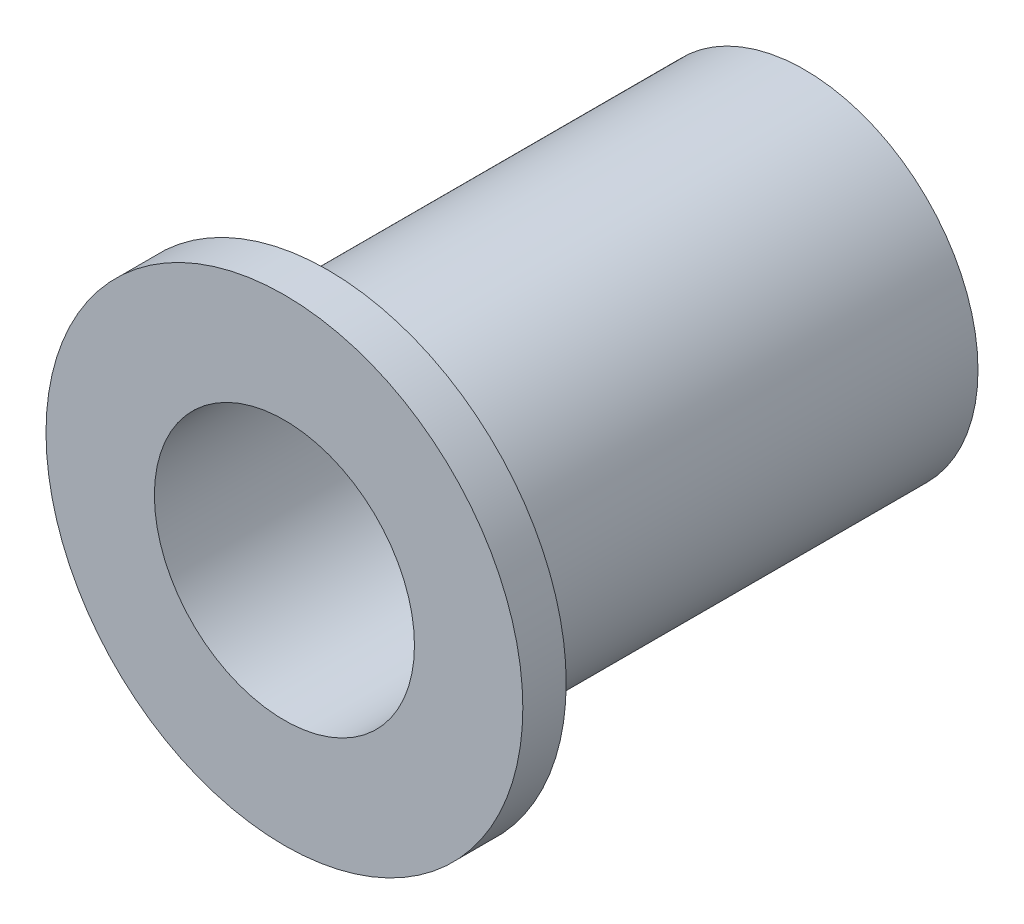
from build123d import *

# Parameters (mm, degrees)
SKETCH1_R           = 6.35
SKETCH1_R_2         = 4.7625
BOSS_EXTRUDE1_DEPTH = 19.05
SKETCH2_R           = 8.73125
SKETCH2_R_2         = 4.7625
BOSS_EXTRUDE2_DEPTH = 1.5875


with BuildPart() as part:
    # Sketch1 → Boss-Extrude1 (new body)
    with BuildSketch(Plane.XY):
        Circle(SKETCH1_R)
        Circle(SKETCH1_R_2, mode=Mode.SUBTRACT)
    extrude(amount=BOSS_EXTRUDE1_DEPTH)

    # Sketch2 → Boss-Extrude2 (add)
    with BuildSketch(Plane.XY.offset(19.05)):
        Circle(SKETCH2_R)
        Circle(SKETCH2_R_2, mode=Mode.SUBTRACT)
    extrude(amount=-BOSS_EXTRUDE2_DEPTH)


solid = part.part
